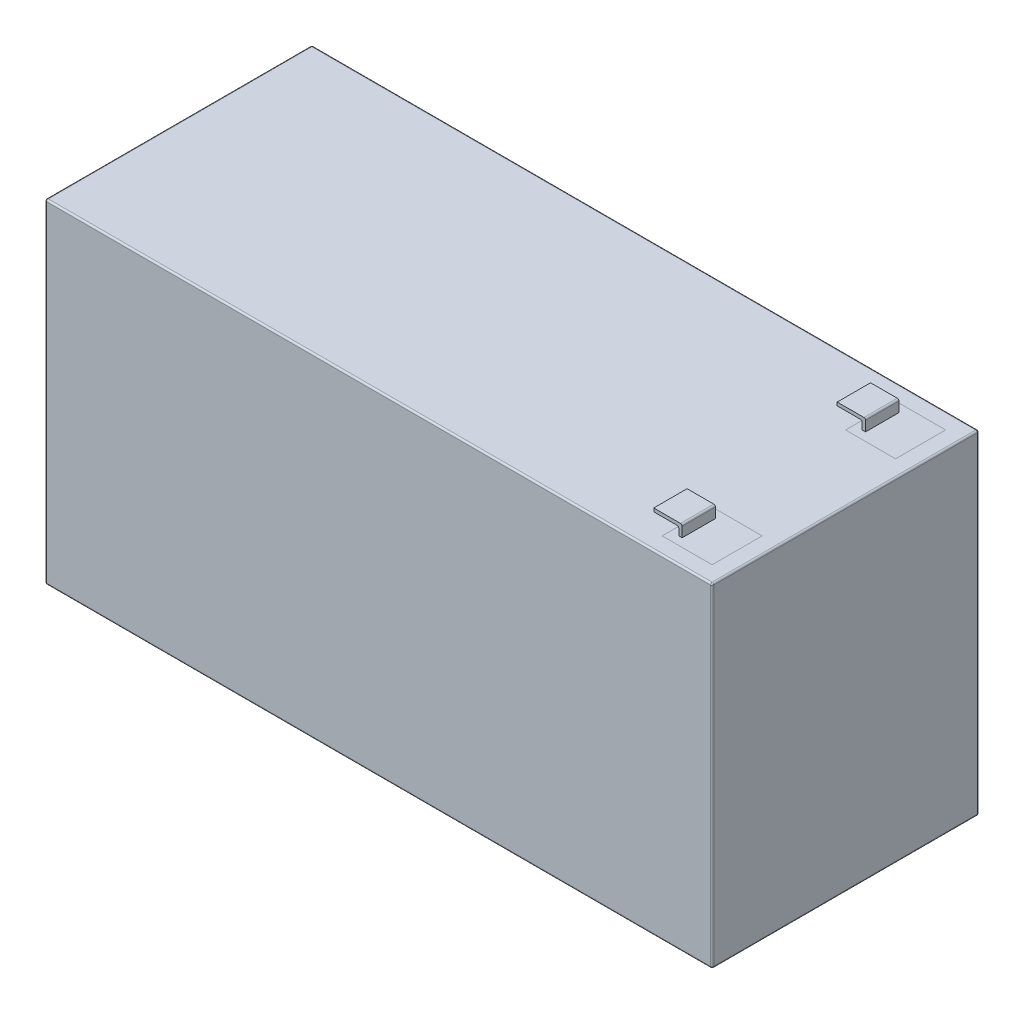
from build123d import *

# Parameters (mm, degrees)
SKETCH1_W           = 101.6
SKETCH1_H           = 40.64
BOSS_EXTRUDE1_DEPTH = 50.8
BOSS_EXTRUDE2_START = -8.89
BOSS_EXTRUDE2_DEPTH = 5.08
FILLET1_R           = 0.254


with BuildPart() as part:
    # Sketch1 → Boss-Extrude1 (new body)
    with BuildSketch(Plane(origin=(0, 0, 0), x_dir=(1, 0, 0), z_dir=(0, 1, 0))):
        Rectangle(SKETCH1_W, SKETCH1_H)
    extrude(amount=BOSS_EXTRUDE1_DEPTH)

    # Sketch3 → Boss-Extrude2 (add)
    with BuildSketch(Plane(origin=(0, 0, -20.32), x_dir=(-1, 0, 0), z_dir=(0, 0, -1)).offset(BOSS_EXTRUDE2_START)):
        Polygon((-42.418, 50.8), (-42.418, 52.578), (-38.09867671, 52.578), (-38.09867671, 52.07), (-41.91, 52.07), (-41.91, 50.8), align=None)
    boss_extrude2 = extrude(amount=BOSS_EXTRUDE2_DEPTH)

    # Mirror1: Boss-Extrude2 across plane
    add(boss_extrude2.mirror(Plane.XY))

    # Fillet1
    fillet1_edges = [part.edges().sort_by_distance(p)[0] for p in [
        (-50.8, 50.8, 0),
        (0, 50.8, 20.32),
        (41.91, 52.07, -13.97),
        (42.418, 52.578, -13.97),
        (50.8, 50.8, 0),
        (0, 0, 20.32),
        (-50.8, 0, 0),
        (42.418, 52.578, 13.97),
        (41.91, 52.07, 13.97),
        (0, 0, -20.32),
        (50.8, 0, 0),
        (0, 50.8, -20.32),
        (50.8, 25.4, 20.32),
        (-50.8, 25.4, 20.32),
        (-50.8, 25.4, -20.32),
        (50.8, 25.4, -20.32),
    ]]
    fillet(fillet1_edges, radius=FILLET1_R)


solid = part.part
